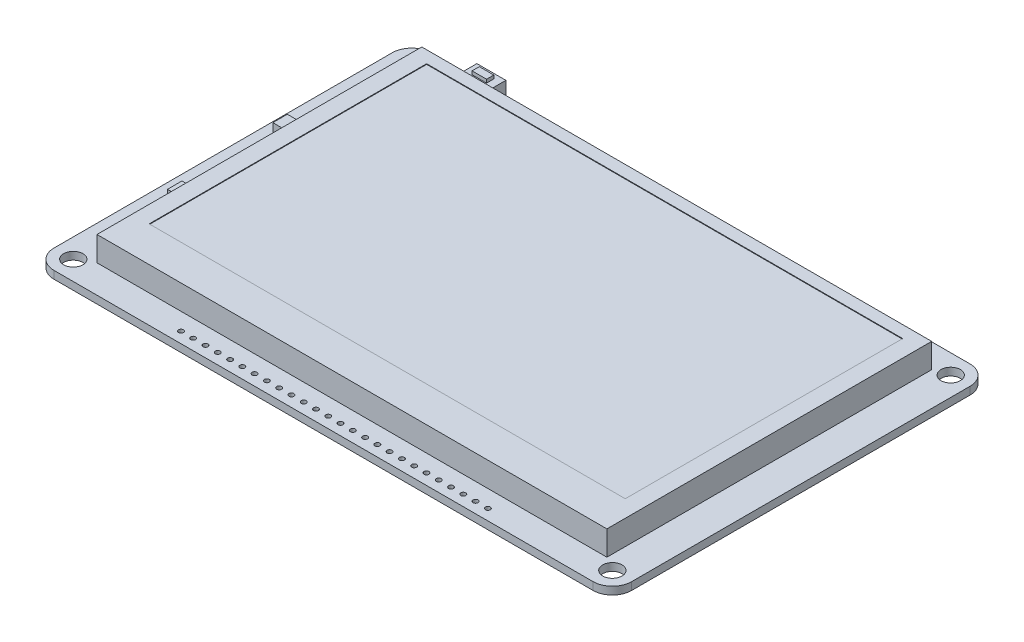
from build123d import *

# Parameters (mm, degrees)
SKETCH1_W           = 119.5324
SKETCH1_H           = 78.0034
BOSS_EXTRUDE1_DEPTH = 1.5875
CUT_EXTRUDE1_REACH  = 3.587
SKETCH2_R           = 2
SKETCH3_R           = 0.508
CUT_EXTRUDE2_DEPTH  = 1.5875
CUT_EXTRUDE4_REACH  = 3.587
LPATTERN1_COUNT     = 26
LPATTERN1_PITCH     = 2.54
SKETCH5_W           = 105.5
SKETCH5_H           = 67.2
BOSS_EXTRUDE2_DEPTH = 5.08
SKETCH6_W           = 98.5
SKETCH6_H           = 57.4
CUT_EXTRUDE3_DEPTH  = 0.127
SKETCH7_W           = 6
SKETCH7_H           = 3.5
BOSS_EXTRUDE3_DEPTH = 3.8
SKETCH8_W           = 3
SKETCH8_H           = 1.5
BOSS_EXTRUDE4_DEPTH = 0.7
SKETCH9_W           = 3
SKETCH9_H           = 3
BOSS_EXTRUDE5_DEPTH = 1.71
SKETCH10_W          = 3
SKETCH10_H          = 3
BOSS_EXTRUDE6_DEPTH = 1


with BuildPart() as part:
    # Sketch1 → Boss-Extrude1 (new body)
    with BuildSketch(Plane(origin=(0, 0, 0), x_dir=(1, 0, 0), z_dir=(0, 1, 0))):
        Rectangle(SKETCH1_W, SKETCH1_H)
    extrude(amount=BOSS_EXTRUDE1_DEPTH)

    # Sketch2 → Cut-Extrude1 (cut, up to next)
    with BuildSketch(Plane(origin=(0, 1.5875, 0), x_dir=(1, 0, 0), z_dir=(0, 1, 0)), mode=Mode.PRIVATE) as cut_extrude1_sk1:
        with Locations((-55.7657, 35.0012)):
            Circle(SKETCH2_R)
    cut_extrude1_tool1 = extrude(cut_extrude1_sk1.sketch, amount=-CUT_EXTRUDE1_REACH, mode=Mode.PRIVATE) & part.part
    add(cut_extrude1_tool1.solids().sort_by_distance((-55.7657, 1.5875, -35.0012))[0], mode=Mode.SUBTRACT)
    # Sketch2 → Cut-Extrude1 (cut, up to next)
    with BuildSketch(Plane(origin=(0, 1.5875, 0), x_dir=(1, 0, 0), z_dir=(0, 1, 0)), mode=Mode.PRIVATE) as cut_extrude1_sk2:
        with Locations((-55.7657, -35.0012)):
            Circle(SKETCH2_R)
    cut_extrude1_tool2 = extrude(cut_extrude1_sk2.sketch, amount=-CUT_EXTRUDE1_REACH, mode=Mode.PRIVATE) & part.part
    add(cut_extrude1_tool2.solids().sort_by_distance((-55.7657, 1.5875, 35.0012))[0], mode=Mode.SUBTRACT)
    # Sketch2 → Cut-Extrude1 (cut, up to next)
    with BuildSketch(Plane(origin=(0, 1.5875, 0), x_dir=(1, 0, 0), z_dir=(0, 1, 0)), mode=Mode.PRIVATE) as cut_extrude1_sk3:
        with Locations((55.7657, 35.0012)):
            Circle(SKETCH2_R)
    cut_extrude1_tool3 = extrude(cut_extrude1_sk3.sketch, amount=-CUT_EXTRUDE1_REACH, mode=Mode.PRIVATE) & part.part
    add(cut_extrude1_tool3.solids().sort_by_distance((55.7657, 1.5875, -35.0012))[0], mode=Mode.SUBTRACT)
    # Sketch2 → Cut-Extrude1 (cut, up to next)
    with BuildSketch(Plane(origin=(0, 1.5875, 0), x_dir=(1, 0, 0), z_dir=(0, 1, 0)), mode=Mode.PRIVATE) as cut_extrude1_sk4:
        with Locations((55.7657, -35.0012)):
            Circle(SKETCH2_R)
    cut_extrude1_tool4 = extrude(cut_extrude1_sk4.sketch, amount=-CUT_EXTRUDE1_REACH, mode=Mode.PRIVATE) & part.part
    add(cut_extrude1_tool4.solids().sort_by_distance((55.7657, 1.5875, 35.0012))[0], mode=Mode.SUBTRACT)

    # Sketch3 → Cut-Extrude2 (cut)
    with BuildSketch(Plane(origin=(0, 1.5875, 0), x_dir=(1, 0, 0), z_dir=(0, 1, 0))):
        with Locations((-31.7373, 36.758)):
            Circle(SKETCH3_R)
        with Locations((-31.7373, -36.758)):
            Circle(SKETCH3_R)
    cut_extrude2 = extrude(amount=-CUT_EXTRUDE2_DEPTH, mode=Mode.SUBTRACT)

    # Sketch11 → Cut-Extrude4 (cut, up to next)
    with BuildSketch(Plane(origin=(0, 1.5875, 0), x_dir=(1, 0, 0), z_dir=(0, 1, 0)), mode=Mode.PRIVATE) as cut_extrude4_sk1:
        with BuildLine():
            Line((-59.7662, 35.0012), (-59.7662, 39.0017))
            Line((-59.7662, 39.0017), (-55.7657, 39.0017))
            ThreePointArc((-55.7657, 39.0017), (-58.594480678, 37.829980678), (-59.7662, 35.0012))
        make_face()
    cut_extrude4_tool1 = extrude(cut_extrude4_sk1.sketch, amount=-CUT_EXTRUDE4_REACH, mode=Mode.PRIVATE) & part.part
    add(cut_extrude4_tool1.solids().sort_by_distance((-58.872617, 1.5875, -38.108117))[0], mode=Mode.SUBTRACT)
    # Sketch11 → Cut-Extrude4 (cut, up to next)
    with BuildSketch(Plane(origin=(0, 1.5875, 0), x_dir=(1, 0, 0), z_dir=(0, 1, 0)), mode=Mode.PRIVATE) as cut_extrude4_sk2:
        with BuildLine():
            Line((-59.7662, -39.0017), (-55.7657, -39.0017))
            ThreePointArc((-55.7657, -39.0017), (-58.594480678, -37.829980678), (-59.7662, -35.0012))
            Line((-59.7662, -35.0012), (-59.7662, -39.0017))
        make_face()
    cut_extrude4_tool2 = extrude(cut_extrude4_sk2.sketch, amount=-CUT_EXTRUDE4_REACH, mode=Mode.PRIVATE) & part.part
    add(cut_extrude4_tool2.solids().sort_by_distance((-58.872617, 1.5875, 38.108117))[0], mode=Mode.SUBTRACT)
    # Sketch11 → Cut-Extrude4 (cut, up to next)
    with BuildSketch(Plane(origin=(0, 1.5875, 0), x_dir=(1, 0, 0), z_dir=(0, 1, 0)), mode=Mode.PRIVATE) as cut_extrude4_sk3:
        with BuildLine():
            Line((59.7662, -35.0012), (59.7662, -39.0017))
            Line((59.7662, -39.0017), (55.7657, -39.0017))
            ThreePointArc((55.7657, -39.0017), (58.594480678, -37.829980678), (59.7662, -35.0012))
        make_face()
    cut_extrude4_tool3 = extrude(cut_extrude4_sk3.sketch, amount=-CUT_EXTRUDE4_REACH, mode=Mode.PRIVATE) & part.part
    add(cut_extrude4_tool3.solids().sort_by_distance((58.872617, 1.5875, 38.108117))[0], mode=Mode.SUBTRACT)
    # Sketch11 → Cut-Extrude4 (cut, up to next)
    with BuildSketch(Plane(origin=(0, 1.5875, 0), x_dir=(1, 0, 0), z_dir=(0, 1, 0)), mode=Mode.PRIVATE) as cut_extrude4_sk4:
        with BuildLine():
            Line((59.7662, 39.0017), (55.7657, 39.0017))
            ThreePointArc((55.7657, 39.0017), (58.594480678, 37.829980678), (59.7662, 35.0012))
            Line((59.7662, 35.0012), (59.7662, 39.0017))
        make_face()
    cut_extrude4_tool4 = extrude(cut_extrude4_sk4.sketch, amount=-CUT_EXTRUDE4_REACH, mode=Mode.PRIVATE) & part.part
    add(cut_extrude4_tool4.solids().sort_by_distance((58.872617, 1.5875, -38.108117))[0], mode=Mode.SUBTRACT)

    # LPattern1: Cut-Extrude2 ×26
    with Locations(*[(i * LPATTERN1_PITCH, 0, 0) for i in range(1, LPATTERN1_COUNT)]):
        add(cut_extrude2, mode=Mode.SUBTRACT)

    # Sketch5 → Boss-Extrude2 (add)
    with BuildSketch(Plane(origin=(0, 1.5875, 0), x_dir=(1, 0, 0), z_dir=(0, 1, 0))):
        with Locations((0.0838, 0.4017)):
            Rectangle(SKETCH5_W, SKETCH5_H)
    extrude(amount=BOSS_EXTRUDE2_DEPTH)

    # Sketch6 → Cut-Extrude3 (cut)
    with BuildSketch(Plane(origin=(0, 6.6675, 0), x_dir=(1, 0, 0), z_dir=(0, 1, 0))):
        with Locations((0.0838, 2.8017)):
            Rectangle(SKETCH6_W, SKETCH6_H)
    extrude(amount=-CUT_EXTRUDE3_DEPTH, mode=Mode.SUBTRACT)

    # Sketch7 → Boss-Extrude3 (add)
    with BuildSketch(Plane(origin=(0, 1.5875, 0), x_dir=(1, 0, 0), z_dir=(0, 1, 0))):
        with Locations((-42.2662, 36.2517)):
            Rectangle(SKETCH7_W, SKETCH7_H)
    extrude(amount=BOSS_EXTRUDE3_DEPTH)

    # Sketch8 → Boss-Extrude4 (add)
    with BuildSketch(Plane(origin=(0, 5.3875, 0), x_dir=(1, 0, 0), z_dir=(0, 1, 0))):
        with Locations((-42.2662, 36.2517)):
            Rectangle(SKETCH8_W, SKETCH8_H)
    extrude(amount=BOSS_EXTRUDE4_DEPTH)

    # Sketch9 → Boss-Extrude5 (add)
    with BuildSketch(Plane(origin=(0, 1.5875, 0), x_dir=(1, 0, 0), z_dir=(0, 1, 0))):
        with Locations((-56.3862, 9.9017)):
            Rectangle(SKETCH9_W, SKETCH9_H)
    extrude(amount=BOSS_EXTRUDE5_DEPTH)

    # Sketch10 → Boss-Extrude6 (add)
    with BuildSketch(Plane(origin=(0, 1.5875, 0), x_dir=(1, 0, 0), z_dir=(0, 1, 0))):
        with Locations((-56.0462, -12.2417)):
            Rectangle(SKETCH10_W, SKETCH10_H)
    extrude(amount=BOSS_EXTRUDE6_DEPTH)


solid = part.part
